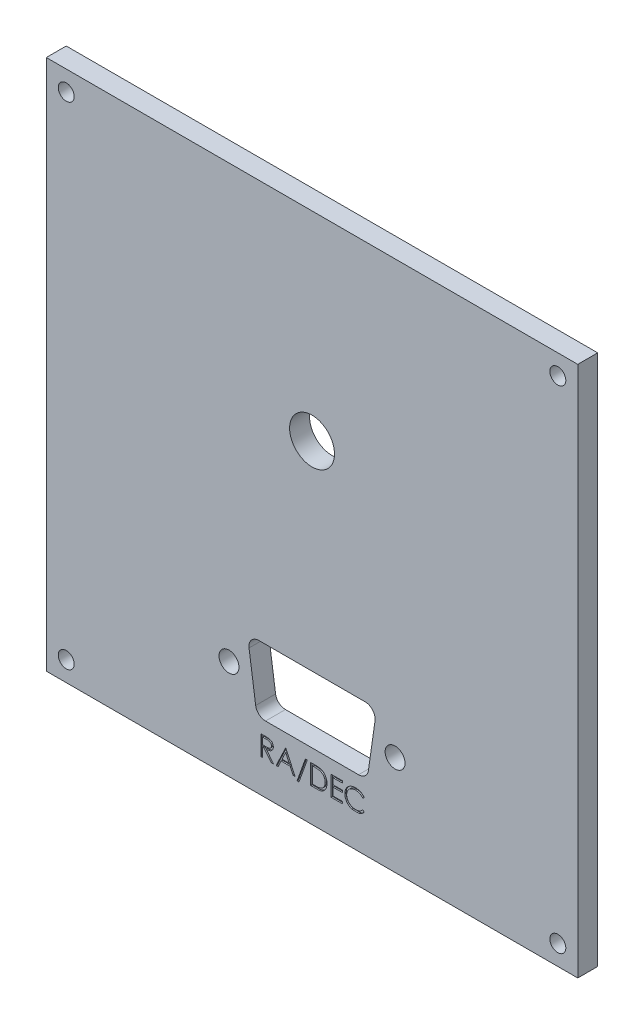
from build123d import *

# Parameters (mm, degrees)
SKETCH_1_W          = 80
SKETCH_1_H          = 80
EXTRUDE_1_DEPTH     = 3
HOLE_WIZARD_M2_1_D  = 2.4
SKETCH_6_R          = 1.5
CUT_EXTRUDE_1_DEPTH = 4
CUT_EXTRUDE_2_DEPTH = 0.2
HOLE_WIZARD_1_4_1_D = 6.7564


with BuildPart() as part:
    # 스케치1 → 보스-돌출1 (new body)
    with BuildSketch(Plane.XY):
        Rectangle(SKETCH_1_W, SKETCH_1_H)
    extrude(amount=EXTRUDE_1_DEPTH)

    # M2 여유 구멍1 (through all)
    with Locations(Plane.XY.offset(3)):
        with Locations((-37, 37), (-37, -37), (37, -37), (37, 37)):
            Hole(HOLE_WIZARD_M2_1_D / 2)

    # 스케치6 → 컷-돌출1 (cut, through all)
    with BuildSketch(Plane.XY.offset(3)):
        with Locations((12.5, -25)):
            Circle(SKETCH_6_R)
        with Locations((-12.5, -25)):
            Circle(SKETCH_6_R)
        with BuildLine():
            ThreePointArc((-8, -20), (-9.133180932, -20.517197388), (-9.48492424, -21.712132034))
            Line((-9.48492424, -21.712132034), (-8.48492424, -28.712132034))
            ThreePointArc((-8.48492424, -28.712132034), (-7.982802612, -29.633180932), (-7, -30))
            Line((-7, -30), (7, -30))
            ThreePointArc((7, -30), (7.982802612, -29.633180932), (8.48492424, -28.712132034))
            Line((8.48492424, -28.712132034), (9.48492424, -21.712132034))
            ThreePointArc((9.48492424, -21.712132034), (9.133180932, -20.517197388), (8, -20))
            Line((8, -20), (-8, -20))
        make_face()
    extrude(amount=-CUT_EXTRUDE_1_DEPTH, mode=Mode.SUBTRACT)

    # 스케치7 → 컷-돌출2 (cut)
    with BuildSketch(Plane.XY.offset(3)):
        with BuildLine():
            Line((-7.711538462, -32), (-7.711538462, -35))
            Line((-7.711538462, -35), (-7.442307692, -35))
            Line((-7.442307692, -35), (-7.442307692, -33.615384615))
            Line((-7.442307692, -33.615384615), (-7.223557692, -33.615384615))
            Line((-7.223557692, -33.615384615), (-6.121394231, -35))
            Line((-6.121394231, -35), (-5.788461538, -35))
            Line((-5.788461538, -35), (-6.890625, -33.615384615))
            add(Edge.make_bspline(
                [(-5.826923077, -32.802283654), (-5.826649603, -32.880130672), (-5.839906644, -32.995695894), (-5.891110429, -33.139042335), (-5.942763806, -33.236893141), (-6.008622951, -33.32510303), (-6.087754764, -33.402580359), (-6.180225752, -33.467414622), (-6.266307761, -33.512374171), (-6.34234854, -33.541168059), (-6.404948517, -33.561427916), (-6.47323449, -33.577080531), (-6.546552245, -33.591105553), (-6.62520664, -33.601684315), (-6.740338511, -33.612384238), (-6.829487108, -33.615159312), (-6.890625, -33.615384615)],
                knots=[0, 0, 0, 0, 0.153720644, 0.22671353, 0.299191166, 0.371189997, 0.443006414, 0.516689173, 0.593217217, 0.633872918, 0.676989142, 0.722899506, 0.771958611, 0.824211323, 0.879378651, 1, 1, 1, 1], degree=3))
            add(Edge.make_bspline(
                [(-6.431490385, -32.040865385), (-6.387792804, -32.050466097), (-6.324253362, -32.070486791), (-6.244004834, -32.105961088), (-6.187608284, -32.136764975), (-6.134693293, -32.17240639), (-6.084705792, -32.212234629), (-6.037421217, -32.256041233), (-5.994751197, -32.304928124), (-5.95451782, -32.35621659), (-5.920584382, -32.411676954), (-5.89133433, -32.469672514), (-5.868040716, -32.530793299), (-5.84930579, -32.594445704), (-5.831312937, -32.684831975), (-5.826799948, -32.754862628), (-5.826923077, -32.802283654)],
                knots=[0, 0, 0, 0, 0.127063766, 0.188744538, 0.249132103, 0.309452533, 0.369826676, 0.430650142, 0.492351932, 0.554072106, 0.615689784, 0.676797703, 0.738439048, 0.80131691, 0.865184512, 1, 1, 1, 1], degree=3))
            add(Edge.make_bspline(
                [(-7.111177885, -32), (-7.034266003, -32.000437876), (-6.924014073, -32.000193762), (-6.783844092, -32.005909111), (-6.693825783, -32.009426109), (-6.61393565, -32.015869967), (-6.527227934, -32.02338295), (-6.467573299, -32.032792047), (-6.431490385, -32.040865385)],
                knots=[0, 0, 0, 0, 0.338434414, 0.484822051, 0.617157578, 0.734698361, 0.837385184, 1, 1, 1, 1], degree=3))
            Line((-7.111177885, -32), (-7.711538462, -32))
        make_face()
        with BuildLine():
            Line((-7.442307692, -33.307692308), (-7.442307692, -32.307692308))
            Line((-7.442307692, -32.307692308), (-6.879807692, -32.307692308))
            add(Edge.make_bspline(
                [(-6.096153846, -32.801682692), (-6.096312159, -32.75399654), (-6.106234025, -32.682024329), (-6.14411893, -32.593698642), (-6.182069204, -32.531845975), (-6.228365105, -32.475697494), (-6.282634652, -32.427657262), (-6.343411305, -32.388014816), (-6.400214996, -32.362682496), (-6.450987207, -32.347151206), (-6.495069766, -32.336221584), (-6.544879603, -32.327440848), (-6.600658583, -32.320404334), (-6.662168481, -32.314361728), (-6.755920999, -32.308682634), (-6.829114974, -32.307521836), (-6.879807692, -32.307692308)],
                knots=[0, 0, 0, 0, 0.136364825, 0.204019354, 0.273063739, 0.34291332, 0.410965444, 0.479168767, 0.549308007, 0.587651576, 0.630646669, 0.678878786, 0.731934299, 0.791111423, 0.85528319, 1, 1, 1, 1], degree=3))
            add(Edge.make_bspline(
                [(-6.893028846, -33.311899038), (-6.843307585, -33.312697472), (-6.771358622, -33.310059728), (-6.678799546, -33.304604817), (-6.617050129, -33.298660662), (-6.560484256, -33.290981096), (-6.509129888, -33.281379223), (-6.462903283, -33.270191582), (-6.408990214, -33.252875946), (-6.348787711, -33.225442197), (-6.283359813, -33.185528918), (-6.227646873, -33.135326817), (-6.180562001, -33.077920986), (-6.142782755, -33.014804247), (-6.10685005, -32.923654117), (-6.095969302, -32.850690314), (-6.096153846, -32.801682692)],
                knots=[0, 0, 0, 0, 0.138913286, 0.20118457, 0.259124428, 0.312255041, 0.36068151, 0.405086143, 0.445101659, 0.51877778, 0.589461579, 0.658462242, 0.727283218, 0.796322487, 0.863174893, 1, 1, 1, 1], degree=3))
            Line((-6.893028846, -33.311899038), (-7.442307692, -33.307692308))
        make_face(mode=Mode.SUBTRACT)
        Polygon((-3.980769231, -32), (-5.403846154, -35), (-5.109975962, -35), (-4.653846154, -34.038461538), (-3.293870192, -34.038461538), (-2.850360577, -35), (-2.557692308, -35), (-3.942307692, -32), align=None)
        Polygon((-4.5078125, -33.730769231), (-3.964543269, -32.584735577), (-3.435697115, -33.730769231), align=None, mode=Mode.SUBTRACT)
        with BuildLine():
            Line((-0.211538462, -32), (-0.211538462, -35))
            Line((-0.211538462, -35), (0.718149038, -35))
            add(Edge.make_bspline(
                [(2.25, -33.537860577), (2.250298882, -33.610958139), (2.243853727, -33.718934206), (2.22497293, -33.860202898), (2.203532601, -33.961008273), (2.177466504, -34.059003761), (2.144070447, -34.153145718), (2.10581098, -34.244297546), (2.061196923, -34.331226813), (2.01221856, -34.413583989), (1.959657075, -34.491220156), (1.903568476, -34.563027489), (1.843417934, -34.629223442), (1.779982749, -34.689708223), (1.712847608, -34.744987095), (1.641839279, -34.793978423), (1.567275802, -34.838607391), (1.486981977, -34.877539053), (1.39943695, -34.910479351), (1.304267365, -34.937775269), (1.201706846, -34.960555137), (1.091578086, -34.978601679), (0.929711968, -34.9953495), (0.804192235, -35.000450708), (0.718149038, -35)],
                knots=[0, 0, 0, 0, 0.0908068, 0.134295271, 0.177024386, 0.218822734, 0.260244116, 0.301079867, 0.341613894, 0.381583419, 0.420119591, 0.458074619, 0.494738488, 0.531194623, 0.566933698, 0.602712651, 0.638326606, 0.674853249, 0.713467371, 0.754441804, 0.797815361, 0.843989456, 0.89307157, 1, 1, 1, 1], degree=3))
            add(Edge.make_bspline(
                [(1.346153846, -32.108173077), (1.415335346, -32.13272179), (1.515515375, -32.177456668), (1.639200958, -32.252808364), (1.725971216, -32.315309852), (1.805511842, -32.386259307), (1.880947977, -32.462591637), (1.949188942, -32.547096562), (2.011681866, -32.638017806), (2.068026551, -32.734285328), (2.117003537, -32.835715405), (2.157676264, -32.941793028), (2.191450006, -33.052223105), (2.218029869, -33.16724876), (2.242753029, -33.329231292), (2.250447131, -33.453701172), (2.25, -33.537860577)],
                knots=[0, 0, 0, 0, 0.121694296, 0.181154855, 0.239875389, 0.298701942, 0.357647424, 0.417604843, 0.478494041, 0.540407051, 0.602344994, 0.665004328, 0.728559309, 0.793650542, 0.860534268, 1, 1, 1, 1], degree=3))
            add(Edge.make_bspline(
                [(0.394230769, -32), (0.496010455, -32.000417849), (0.643205153, -32.002555011), (0.831906882, -32.01398617), (0.956567167, -32.025943863), (1.070110373, -32.040684154), (1.19980081, -32.063925522), (1.290428269, -32.088445092), (1.346153846, -32.108173077)],
                knots=[0, 0, 0, 0, 0.317405911, 0.458843612, 0.589366542, 0.707831319, 0.815770031, 1, 1, 1, 1], degree=3))
            Line((0.394230769, -32), (-0.211538462, -32))
        make_face()
        with BuildLine():
            Line((0.402043269, -34.692307692), (0.057692308, -34.692307692))
            Line((0.057692308, -34.692307692), (0.057692308, -32.307692308))
            Line((0.057692308, -32.307692308), (0.268629808, -32.307692308))
            add(Edge.make_bspline(
                [(1.190504808, -32.391826923), (1.137346775, -32.375749539), (1.050420451, -32.357545846), (0.926312793, -32.339741376), (0.816695321, -32.327647747), (0.695801907, -32.31902402), (0.511934137, -32.309938058), (0.368211796, -32.307360443), (0.268629808, -32.307692308)],
                knots=[0, 0, 0, 0, 0.179284514, 0.286582528, 0.405111483, 0.535592873, 0.67819021, 1, 1, 1, 1], degree=3))
            add(Edge.make_bspline(
                [(1.980769231, -33.537259615), (1.981562127, -33.46831221), (1.97439289, -33.366743947), (1.952700908, -33.234843634), (1.929774649, -33.141433357), (1.900511484, -33.051700587), (1.864003917, -32.966140978), (1.822289108, -32.883851105), (1.772657832, -32.806730192), (1.718301549, -32.733793338), (1.65797774, -32.666974488), (1.592644276, -32.606123523), (1.523015471, -32.550284998), (1.447122501, -32.501734391), (1.338615083, -32.442965489), (1.250551099, -32.41049979), (1.190504808, -32.391826923)],
                knots=[0, 0, 0, 0, 0.137812606, 0.203226247, 0.267174055, 0.330024003, 0.391794272, 0.453084399, 0.514333908, 0.574999993, 0.634865483, 0.694116315, 0.753441622, 0.8131258, 0.874079686, 1, 1, 1, 1], degree=3))
            add(Edge.make_bspline(
                [(1.259615385, -34.615985577), (1.313857278, -34.597589777), (1.393743745, -34.566905325), (1.491659203, -34.51133046), (1.560327438, -34.46557008), (1.624035332, -34.413584321), (1.683541899, -34.356524409), (1.738726245, -34.294094349), (1.789018548, -34.226373137), (1.834025564, -34.153781866), (1.873001272, -34.077034294), (1.907158334, -33.996971332), (1.933973913, -33.912363405), (1.954966488, -33.823967369), (1.975266254, -33.698908287), (1.980794662, -33.602516929), (1.980769231, -33.537259615)],
                knots=[0, 0, 0, 0, 0.123338231, 0.183124538, 0.241782995, 0.300578883, 0.359680075, 0.418881641, 0.479530664, 0.540850536, 0.602303396, 0.664463212, 0.727805723, 0.792894815, 0.859672328, 1, 1, 1, 1], degree=3))
            add(Edge.make_bspline(
                [(0.402043269, -34.692307692), (0.497207805, -34.692261137), (0.63411568, -34.690445821), (0.808584166, -34.682225314), (0.921834474, -34.674035186), (1.023214273, -34.663137927), (1.135448428, -34.6481482), (1.21284286, -34.630723896), (1.259615385, -34.615985577)],
                knots=[0, 0, 0, 0, 0.330627932, 0.475548836, 0.60674619, 0.725023803, 0.829742387, 1, 1, 1, 1], degree=3))
        make_face(mode=Mode.SUBTRACT)
        with BuildLine():
            add(Edge.make_bspline(
                [(6.008721263, -35), (5.984815812, -34.992686757), (5.934265042, -34.976215786), (5.858651199, -34.946695828), (5.782314397, -34.91196757), (5.708716537, -34.872717936), (5.637893312, -34.829275346), (5.569141534, -34.782603312), (5.503502475, -34.731180377), (5.418755068, -34.656915002), (5.359642488, -34.59569858), (5.322716346, -34.552283654)],
                knots=[0.402205172, 0.402205172, 0.402205172, 0.402205172, 0.456180032, 0.516995649, 0.577395938, 0.637198344, 0.696999184, 0.756756194, 0.816553905, 0.876947997, 1, 1, 1, 1], degree=3))
            Line((6.008721263, -35), (7.08786423, -35))
            add(Edge.make_bspline(
                [(7.865384615, -34.447716346), (7.828267547, -34.497041883), (7.769270922, -34.567908701), (7.682815714, -34.654497445), (7.614553916, -34.714617482), (7.543306187, -34.771318445), (7.467816685, -34.823006502), (7.389071515, -34.870398472), (7.307339182, -34.913793066), (7.222706063, -34.952293429), (7.149016753, -34.980073309), (7.103723665, -34.995025613), (7.08786423, -35)],
                knots=[0, 0, 0, 0, 0.123053062, 0.183475001, 0.243726501, 0.304278917, 0.364862921, 0.425946204, 0.48739123, 0.549220384, 0.611143589, 0.644270548, 0.644270548, 0.644270548, 0.644270548], degree=3))
            Line((7.865384615, -34.447716346), (7.629807692, -34.269230769))
            add(Edge.make_bspline(
                [(6.558293269, -34.769230769), (6.661299731, -34.769259335), (6.814300675, -34.754731757), (7.009639121, -34.701615947), (7.14791537, -34.646910622), (7.279308496, -34.57566797), (7.448659494, -34.458828577), (7.56062735, -34.34880047), (7.629807692, -34.269230769)],
                knots=[0, 0, 0, 0, 0.252948636, 0.374754734, 0.495939754, 0.617180641, 0.740909469, 1, 1, 1, 1], degree=3))
            add(Edge.make_bspline(
                [(5.211538462, -33.503004808), (5.211139134, -33.59009195), (5.223269325, -33.718707511), (5.262399071, -33.884081669), (5.305392468, -34.000122096), (5.358478888, -34.111471966), (5.425538763, -34.216248171), (5.503211044, -34.31603377), (5.592588851, -34.408470649), (5.690651051, -34.492910744), (5.795863529, -34.56726927), (5.907964347, -34.629250192), (6.025715762, -34.68084185), (6.150023788, -34.720443518), (6.32717346, -34.758538662), (6.46489475, -34.769982169), (6.558293269, -34.769230769)],
                knots=[0, 0, 0, 0, 0.126290104, 0.186726469, 0.246146432, 0.305575643, 0.365429386, 0.426326309, 0.488839906, 0.551724972, 0.613918596, 0.675483766, 0.737333897, 0.800229044, 0.864502298, 1, 1, 1, 1], degree=3))
            add(Edge.make_bspline(
                [(6.539663462, -32.230769231), (6.479765076, -32.2299807), (6.390636818, -32.236408037), (6.273704742, -32.253702852), (6.188237071, -32.272637597), (6.104594723, -32.296622125), (6.022229757, -32.325270348), (5.94233497, -32.360717928), (5.863805048, -32.39989628), (5.788565725, -32.444148417), (5.717375684, -32.492416994), (5.650494569, -32.544161937), (5.587869473, -32.59957717), (5.529436375, -32.658413136), (5.475618677, -32.721296857), (5.426602621, -32.788027292), (5.381416562, -32.857724498), (5.340948646, -32.930185465), (5.307065368, -33.005678373), (5.277062938, -33.082910496), (5.253313312, -33.162754215), (5.234548829, -33.244648516), (5.216951494, -33.357937958), (5.210807044, -33.444514247), (5.211538462, -33.503004808)],
                knots=[0, 0, 0, 0, 0.087501875, 0.130462627, 0.172752021, 0.215403067, 0.25764983, 0.300152749, 0.34312149, 0.385925163, 0.427685727, 0.46881795, 0.5094918, 0.549883031, 0.589980023, 0.63040523, 0.670868626, 0.711383944, 0.751627258, 0.791775577, 0.832458919, 0.873319045, 0.914542956, 1, 1, 1, 1], degree=3))
            add(Edge.make_bspline(
                [(7.629807692, -32.730769231), (7.597021182, -32.690509402), (7.545059971, -32.632903973), (7.469928813, -32.562753107), (7.411724556, -32.513678979), (7.350213512, -32.469610134), (7.286905112, -32.428233827), (7.22073514, -32.391148863), (7.129233671, -32.346173055), (7.009535932, -32.299305365), (6.805988093, -32.245829433), (6.646950148, -32.230248139), (6.539663462, -32.230769231)],
                knots=[0, 0, 0, 0, 0.125474941, 0.18712122, 0.248294346, 0.309294856, 0.369850066, 0.430973376, 0.49245599, 0.616147966, 0.740843698, 1, 1, 1, 1], degree=3))
            Line((7.629807692, -32.730769231), (7.865384615, -32.550480769))
            add(Edge.make_bspline(
                [(6.556490385, -31.923076923), (6.62470097, -31.922947588), (6.725949617, -31.927580181), (6.858384911, -31.945596927), (6.954051108, -31.963677909), (7.047584873, -31.986146186), (7.13827077, -32.015408013), (7.226641075, -32.04886824), (7.312138438, -32.08740397), (7.394352571, -32.130661231), (7.473258184, -32.178160217), (7.548227336, -32.229842756), (7.619791883, -32.285266794), (7.686738643, -32.345614167), (7.772668573, -32.430590287), (7.82921923, -32.501857359), (7.865384615, -32.550480769)],
                knots=[0, 0, 0, 0, 0.135682946, 0.20121499, 0.265682235, 0.329266835, 0.392395428, 0.455069762, 0.51712685, 0.578790035, 0.639739863, 0.700191504, 0.759806243, 0.819628319, 0.879354791, 1, 1, 1, 1], degree=3))
            add(Edge.make_bspline(
                [(4.942307692, -33.482572115), (4.942253757, -33.376455961), (4.955705069, -33.219170568), (5.004431124, -33.017364147), (5.055290926, -32.874904769), (5.119852148, -32.738507128), (5.199585507, -32.609214733), (5.293586939, -32.486200331), (5.401113142, -32.371330483), (5.519028073, -32.266297), (5.64530134, -32.173890774), (5.779685804, -32.096993397), (5.920701358, -32.032698416), (6.069402407, -31.983336505), (6.280751379, -31.936250069), (6.445230429, -31.923293086), (6.556490385, -31.923076923)],
                knots=[0, 0, 0, 0, 0.127013532, 0.18795481, 0.248013913, 0.307747682, 0.368234515, 0.429469844, 0.492743437, 0.556257769, 0.618216786, 0.679655476, 0.741245546, 0.803415265, 0.866815462, 1, 1, 1, 1], degree=3))
            add(Edge.make_bspline(
                [(5.322716346, -34.552283654), (5.260544465, -34.479650735), (5.176992607, -34.363261153), (5.088617519, -34.194956505), (5.035102959, -34.063485939), (4.993363557, -33.926310783), (4.953956804, -33.733064021), (4.942009217, -33.583579654), (4.942307692, -33.482572115)],
                knots=[0, 0, 0, 0, 0.247156016, 0.368779749, 0.490733862, 0.613613772, 0.738957576, 1, 1, 1, 1], degree=3))
        make_face()
        Polygon((2.865384615, -32), (2.865384615, -35), (4.557692308, -35), (4.557692308, -34.692307692), (3.134615385, -34.692307692), (3.134615385, -33.538461538), (4.557692308, -33.538461538), (4.557692308, -33.230769231), (3.134615385, -33.230769231), (3.134615385, -32.307692308), (4.557692308, -32.307692308), (4.557692308, -32), align=None)
        Polygon((-0.995192308, -31.923076923), (-2.098319949, -35), (-1.814666103, -35), (-0.711538462, -31.923076923), align=None)
        Polygon((-1.814666103, -35), (-2.098319949, -35), (-2.25, -35.423076923), (-1.966346154, -35.423076923), align=None)
    extrude(amount=-CUT_EXTRUDE_2_DEPTH, mode=Mode.SUBTRACT)

    # 1/4 여유 구멍1 (through all)
    with Locations(Plane.XY.offset(3)):
        with Locations((0, 10)):
            Hole(HOLE_WIZARD_1_4_1_D / 2)


solid = part.part
